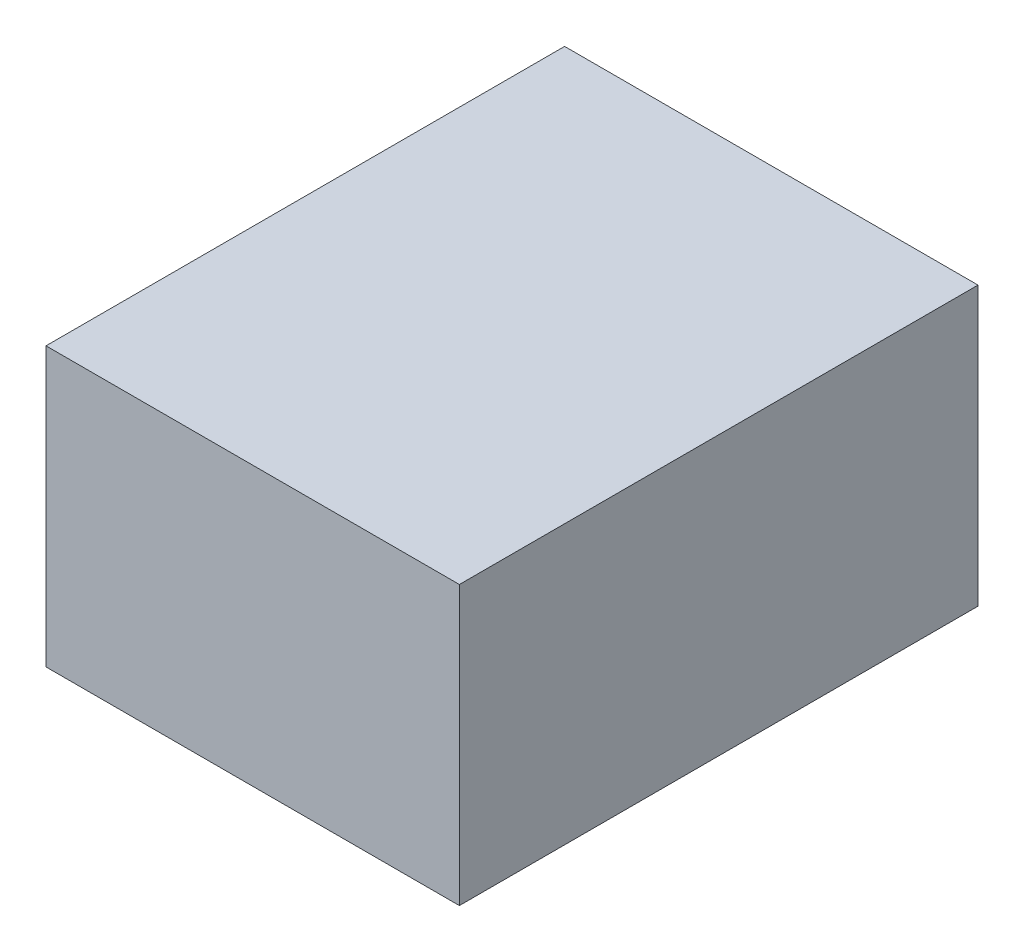
from build123d import *

# Parameters (mm, degrees)
SKETCH_1_W      = 55
SKETCH_1_H      = 37
EXTRUDE_1_DEPTH = 69


with BuildPart() as part:
    # 草图1 → 凸台-拉伸1 (new body)
    with BuildSketch(Plane.XY):
        Rectangle(SKETCH_1_W, SKETCH_1_H)
    extrude(amount=EXTRUDE_1_DEPTH)


solid = part.part
